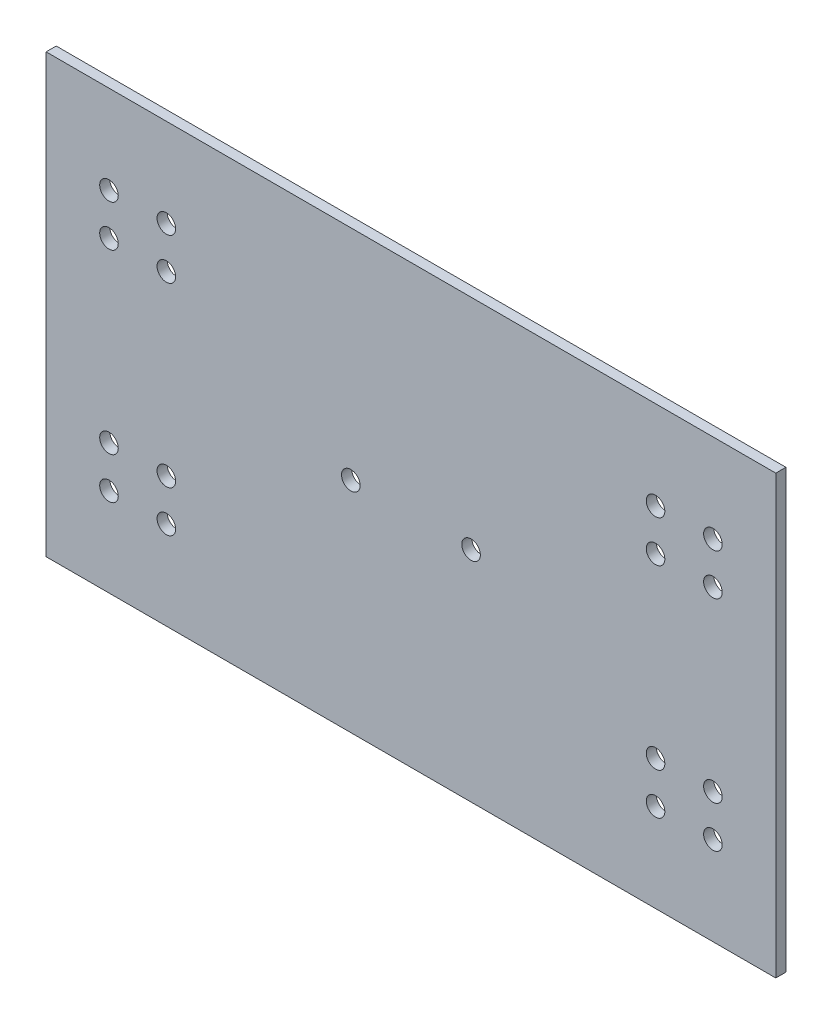
from build123d import *

# Parameters (mm, degrees)
SKETCH1_W           = 267
SKETCH1_H           = 160
SKETCH1_R           = 3.4
BOSS_EXTRUDE1_DEPTH = 3.7


with BuildPart() as part:
    # Sketch1 → Boss-Extrude1 (new body)
    with BuildSketch(Plane.XY):
        with Locations((133.5, 80)):
            Rectangle(SKETCH1_W, SKETCH1_H)
        with Locations((23, 47.6)):
            Circle(SKETCH1_R, mode=Mode.SUBTRACT)
        with Locations((44, 47.6)):
            Circle(SKETCH1_R, mode=Mode.SUBTRACT)
        with Locations((23, 32.4)):
            Circle(SKETCH1_R, mode=Mode.SUBTRACT)
        with Locations((44, 32.4)):
            Circle(SKETCH1_R, mode=Mode.SUBTRACT)
        with Locations((223, 32.4)):
            Circle(SKETCH1_R, mode=Mode.SUBTRACT)
        with Locations((223, 47.6)):
            Circle(SKETCH1_R, mode=Mode.SUBTRACT)
        with Locations((244, 47.6)):
            Circle(SKETCH1_R, mode=Mode.SUBTRACT)
        with Locations((244, 32.4)):
            Circle(SKETCH1_R, mode=Mode.SUBTRACT)
        with Locations((23, 127.6)):
            Circle(SKETCH1_R, mode=Mode.SUBTRACT)
        with Locations((23, 112.4)):
            Circle(SKETCH1_R, mode=Mode.SUBTRACT)
        with Locations((44, 112.4)):
            Circle(SKETCH1_R, mode=Mode.SUBTRACT)
        with Locations((44, 127.6)):
            Circle(SKETCH1_R, mode=Mode.SUBTRACT)
        with Locations((223, 112.4)):
            Circle(SKETCH1_R, mode=Mode.SUBTRACT)
        with Locations((223, 127.6)):
            Circle(SKETCH1_R, mode=Mode.SUBTRACT)
        with Locations((244, 127.6)):
            Circle(SKETCH1_R, mode=Mode.SUBTRACT)
        with Locations((244, 112.4)):
            Circle(SKETCH1_R, mode=Mode.SUBTRACT)
        with Locations((111.5, 80)):
            Circle(SKETCH1_R, mode=Mode.SUBTRACT)
        with Locations((155.5, 80)):
            Circle(SKETCH1_R, mode=Mode.SUBTRACT)
    extrude(amount=BOSS_EXTRUDE1_DEPTH)


solid = part.part
